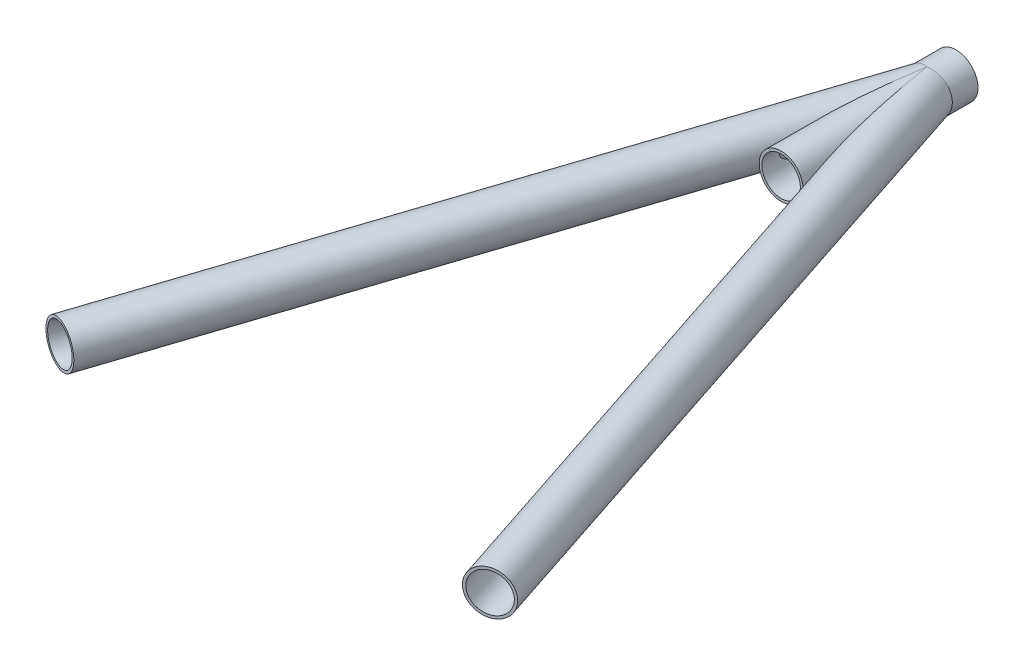
from build123d import *

# Parameters (mm, degrees)
SKETCH2_R               = 9.525
SKETCH2_R_2             = 8.382
BOSS_EXTRUDE1_DEPTH     = 76.2
SWEEP_THIN5_PROFILE_R   = 9.525
SWEEP_THIN5_PROFILE_R_2 = 8.382
SWEEP_THIN6_PROFILE_R   = 9.525
SWEEP_THIN6_PROFILE_R_2 = 8.382


with BuildPart() as part:
    # Sketch2 → Boss-Extrude1 (new body)
    with BuildSketch(Plane.XY.offset(25.4)):
        Circle(SKETCH2_R)
        Circle(SKETCH2_R_2, mode=Mode.SUBTRACT)
    extrude(amount=BOSS_EXTRUDE1_DEPTH)

    # Sweep-Thin5: sweep along a path in Sketch46
    with BuildLine(Plane(origin=(0, 0, 0), x_dir=(1, 0, 0), z_dir=(0, 1, 0))) as sweep_thin5_path:
        Line((0, -38.1), (-93.64245522, -321.953692385))
    # Sweep-Thin5 profile (on start of the path) → Sweep-Thin5 (sweep)
    with BuildSketch(Plane(origin=(0, 0, 38.1), x_dir=(0.9496577801280877, 0, 0.3132891645783379), z_dir=(-0.3132891645783379, 0, 0.9496577801280877))):
        Circle(SWEEP_THIN5_PROFILE_R)
        Circle(SWEEP_THIN5_PROFILE_R_2, mode=Mode.SUBTRACT)
    sweep(path=sweep_thin5_path.line)

    # Sweep-Thin6: sweep along a path in Sketch3
    with BuildLine(Plane(origin=(0, 0, 0), x_dir=(1, 0, 0), z_dir=(0, 1, 0))) as sweep_thin6_path:
        Line((0, -38.1), (93.64245522, -321.953692385))
    # Sweep-Thin6 profile (on start of the path) → Sweep-Thin6 (sweep)
    with BuildSketch(Plane(origin=(0, 0, 38.1), x_dir=(0.9496577801280874, 0, -0.3132891645783382), z_dir=(0.3132891645783382, 0, 0.9496577801280874))):
        Circle(SWEEP_THIN6_PROFILE_R)
        Circle(SWEEP_THIN6_PROFILE_R_2, mode=Mode.SUBTRACT)
    sweep(path=sweep_thin6_path.line)


solid = part.part
